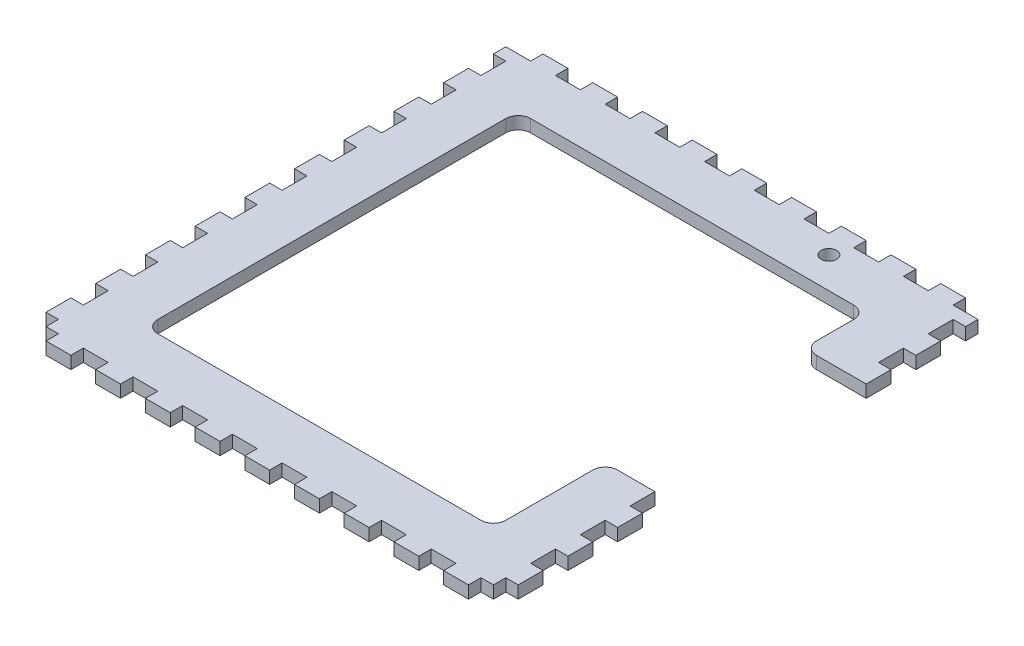
from build123d import *

# Parameters (mm, degrees)
SKETCH1_W               = 241.3
SKETCH1_H               = 254
BOSS_EXTRUDE1_DEPTH     = 6.35
SKETCH2_W               = 6.35
SKETCH2_H               = 12.7
CUT_EXTRUDE1_DEPTH      = 7.35
LPATTERN1_COUNT         = 10
LPATTERN1_PITCH         = 25.4
SKETCH3_W               = 12.7
SKETCH3_H               = 6.35
CUT_EXTRUDE2_DEPTH      = 7.35
LPATTERN2_COUNT         = 10
LPATTERN2_PITCH         = 25.4
SKETCH4_W               = 177.8
SKETCH4_H               = 190.5
CUT_EXTRUDE3_DEPTH      = 7.35
SKETCH5_W               = 101.6
SKETCH5_H               = 6.35
CUT_EXTRUDE4_DEPTH      = 7.35
CUT_EXTRUDE4_DEPTH_BACK = 76.2
FILLET1_R               = 6.35
SKETCH6_R               = 3.96875
CUT_EXTRUDE5_DEPTH      = 115.3


with BuildPart() as part:
    # Sketch1 → Boss-Extrude1 (new body)
    with BuildSketch(Plane(origin=(0, 0, 0), x_dir=(1, 0, 0), z_dir=(0, 1, 0))):
        with Locations((120.65, 127)):
            Rectangle(SKETCH1_W, SKETCH1_H)
    extrude(amount=BOSS_EXTRUDE1_DEPTH)

    # Sketch2 → Cut-Extrude1 (cut, through all)
    with BuildSketch(Plane(origin=(0, 6.35, 0), x_dir=(1, 0, 0), z_dir=(0, 1, 0))):
        with Locations((3.175, 6.35)):
            Rectangle(SKETCH2_W, SKETCH2_H)
        with Locations((238.125, 6.35)):
            Rectangle(SKETCH2_W, SKETCH2_H)
    cut_extrude1 = extrude(amount=-CUT_EXTRUDE1_DEPTH, mode=Mode.SUBTRACT)

    # LPattern1: Cut-Extrude1 ×10
    with Locations(*[(0, 0, -i * LPATTERN1_PITCH) for i in range(1, LPATTERN1_COUNT)]):
        add(cut_extrude1, mode=Mode.SUBTRACT)

    # Sketch3 → Cut-Extrude2 (cut, through all)
    with BuildSketch(Plane(origin=(0, 6.35, 0), x_dir=(1, 0, 0), z_dir=(0, 1, 0))):
        with Locations((6.35, 3.175)):
            Rectangle(SKETCH3_W, SKETCH3_H)
        with Locations((6.35, 250.825)):
            Rectangle(SKETCH3_W, SKETCH3_H)
    cut_extrude2 = extrude(amount=-CUT_EXTRUDE2_DEPTH, mode=Mode.SUBTRACT)

    # LPattern2: Cut-Extrude2 ×10
    with Locations(*[(i * LPATTERN2_PITCH, 0, 0) for i in range(1, LPATTERN2_COUNT)]):
        add(cut_extrude2, mode=Mode.SUBTRACT)

    # Sketch4 → Cut-Extrude3 (cut, through all)
    with BuildSketch(Plane(origin=(0, 6.35, 0), x_dir=(1, 0, 0), z_dir=(0, 1, 0))):
        with Locations((120.65, 127)):
            Rectangle(SKETCH4_W, SKETCH4_H)
    extrude(amount=-CUT_EXTRUDE3_DEPTH, mode=Mode.SUBTRACT)

    # Sketch5 → Cut-Extrude4 (cut, two sides)
    with BuildSketch(Plane(origin=(234.95, 0, 0), x_dir=(0, 0, -1), z_dir=(1, 0, 0))) as cut_extrude4_sk:
        with Locations((139.7, 3.175)):
            Rectangle(SKETCH5_W, SKETCH5_H)
    extrude(amount=CUT_EXTRUDE4_DEPTH, mode=Mode.SUBTRACT)
    extrude(cut_extrude4_sk.sketch, amount=-CUT_EXTRUDE4_DEPTH_BACK, mode=Mode.SUBTRACT)

    # Fillet1
    fillet1_edges = [part.edges().sort_by_distance(p)[0] for p in [
        (31.75, 3.175, -31.75),
        (31.75, 3.175, -222.25),
        (209.55, 3.175, -222.25),
        (209.55, 3.175, -31.75),
        (209.55, 3.175, -88.9),
        (209.55, 3.175, -190.5),
    ]]
    fillet(fillet1_edges, radius=FILLET1_R)

    # Sketch6 → Cut-Extrude5 (cut, through all)
    with BuildSketch(Plane.XZ.offset(107.95)):
        with Locations((174.625, -238.125)):
            Circle(SKETCH6_R)
    extrude(amount=-CUT_EXTRUDE5_DEPTH, mode=Mode.SUBTRACT)


solid = part.part
